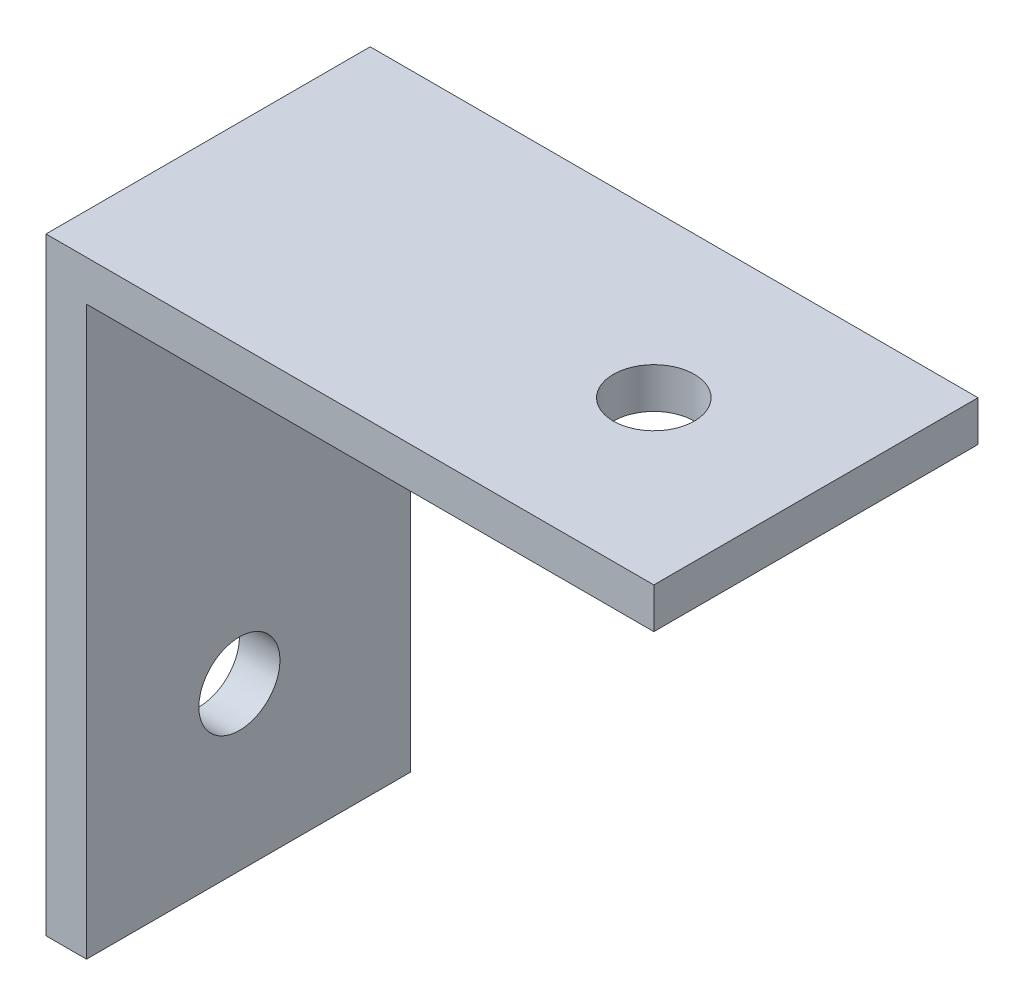
from build123d import *

# Parameters (mm, degrees)
EXTRUDE_1_DEPTH     = 16
SKETCH_2_R          = 2
CUT_EXTRUDE_1_DEPTH = 16
SKETCH_3_R          = 2
CUT_EXTRUDE_2_DEPTH = 16


with BuildPart() as part:
    # 草图1 → 凸台-拉伸1 (new body)
    with BuildSketch(Plane.XY):
        Polygon((-27.281673393, 17.814060708), (-27.281673393, -12.185939292), (-25.281673393, -12.185939292), (-25.281673393, 15.814060708), (2.718326607, 15.814060708), (2.718326607, 17.814060708), align=None)
    extrude(amount=EXTRUDE_1_DEPTH)

    # 草图2 → 切除-拉伸1 (cut)
    with BuildSketch(Plane(origin=(0, 17.814060708, 0), x_dir=(1, 0, 0), z_dir=(0, 1, 0))):
        with Locations((-5.281673393, -8)):
            Circle(SKETCH_2_R)
    extrude(amount=-CUT_EXTRUDE_1_DEPTH, mode=Mode.SUBTRACT)

    # 草图3 → 切除-拉伸2 (cut)
    with BuildSketch(Plane.ZY.offset(27.281673393)):
        with Locations((8.454389853, -4.181246288)):
            Circle(SKETCH_3_R)
    extrude(amount=-CUT_EXTRUDE_2_DEPTH, mode=Mode.SUBTRACT)


solid = part.part
